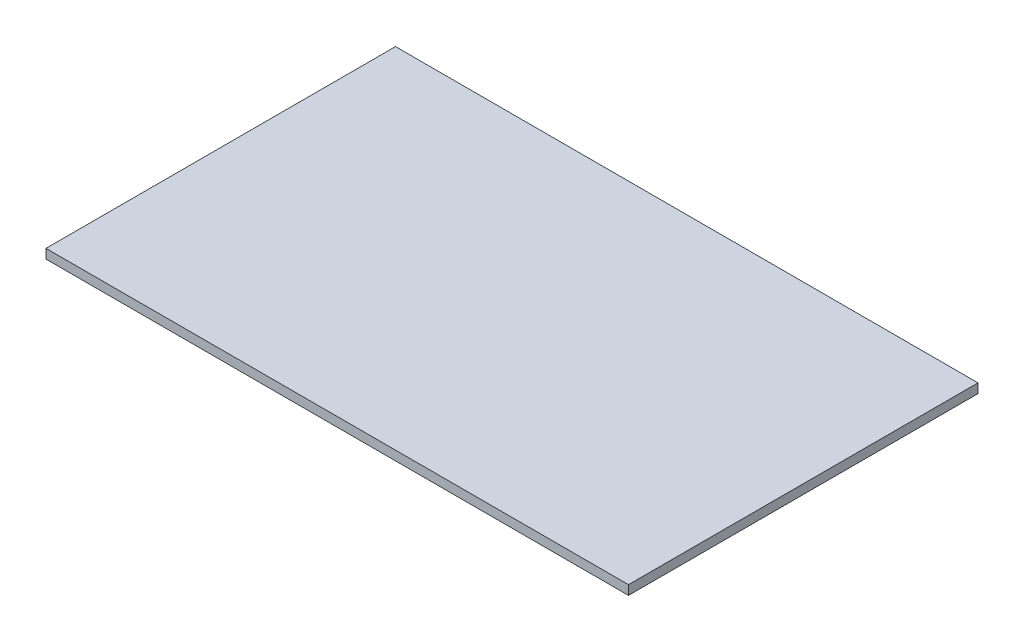
from build123d import *

# Parameters (mm, degrees)
SKETCH1_W           = 100
SKETCH1_H           = 60
BOSS_EXTRUDE1_DEPTH = 1.6


with BuildPart() as part:
    # Sketch1 → Boss-Extrude1 (new body)
    with BuildSketch(Plane(origin=(0, 0, 0), x_dir=(1, 0, 0), z_dir=(0, 1, 0))):
        Rectangle(SKETCH1_W, SKETCH1_H)
    extrude(amount=BOSS_EXTRUDE1_DEPTH)


solid = part.part
